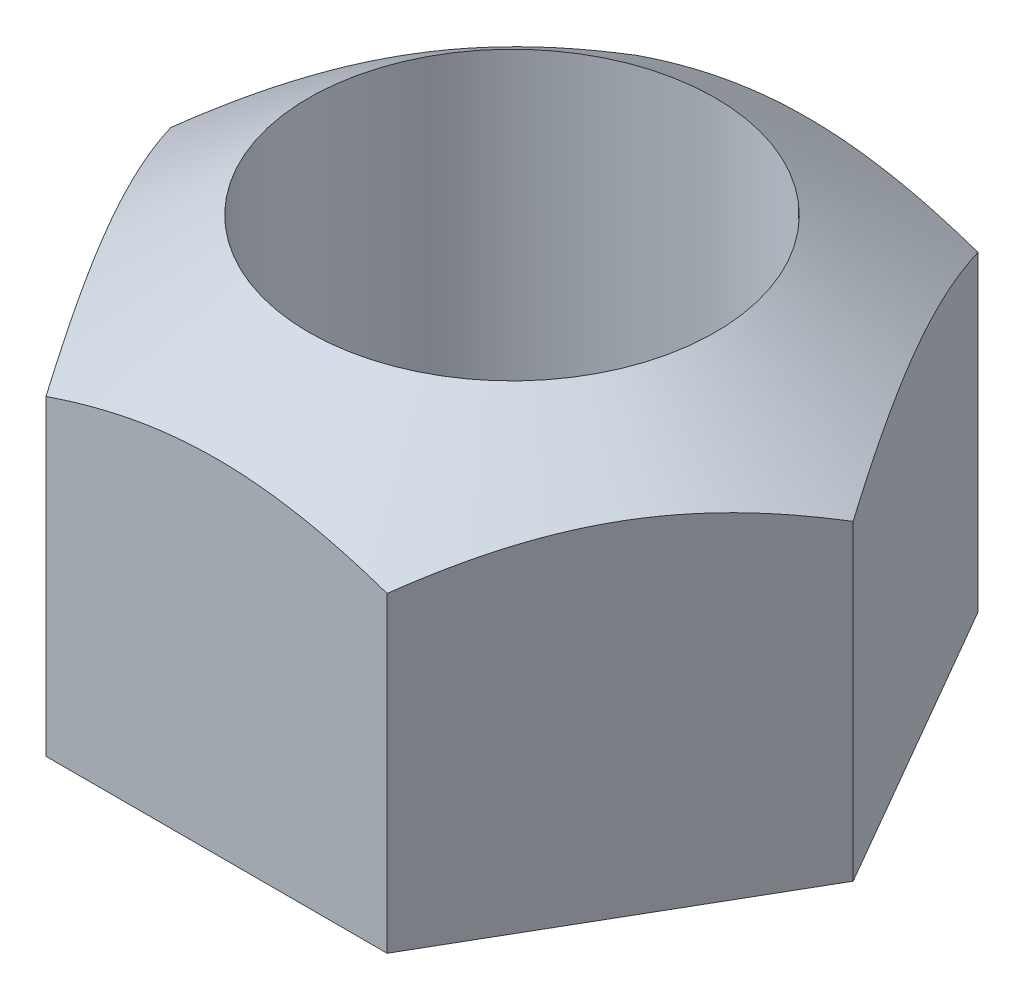
from build123d import *

# Parameters (mm, degrees)
SKETCH_1_R      = 1.5
EXTRUDE_1_DEPTH = 3
SCALE_1_SCALE   = 0.58


with BuildPart() as part:
    # 草图1 → 凸台-拉伸1 (new body)
    with BuildSketch(Plane(origin=(0, 0, 0), x_dir=(1, 0, 0), z_dir=(0, 1, 0))):
        Polygon((2.51866206, 0), (1.25933103, 2.181225328), (-1.25933103, 2.181225328), (-2.51866206, 0), (-1.25933103, -2.181225328), (1.25933103, -2.181225328), align=None)
        Circle(SKETCH_1_R, mode=Mode.SUBTRACT)
    extrude(amount=EXTRUDE_1_DEPTH)

    # 草图2 → 切除-旋转1 (revolve, cut)
    with BuildSketch(Plane.XY):
        Polygon((1.5, 3), (2.51866206, 2.300955063), (2.51866206, 3), align=None)
    revolve(axis=Axis((0, 3.302801136, 0), (0, -1, 0)), mode=Mode.SUBTRACT)


with BuildPart() as part_1:
    # 缩放比例1: scaled about (0, 1.357333829, 0)
    add(part.part.scale(SCALE_1_SCALE).moved(Location((0, 0.570080208, 0))))


solid = part_1.part
